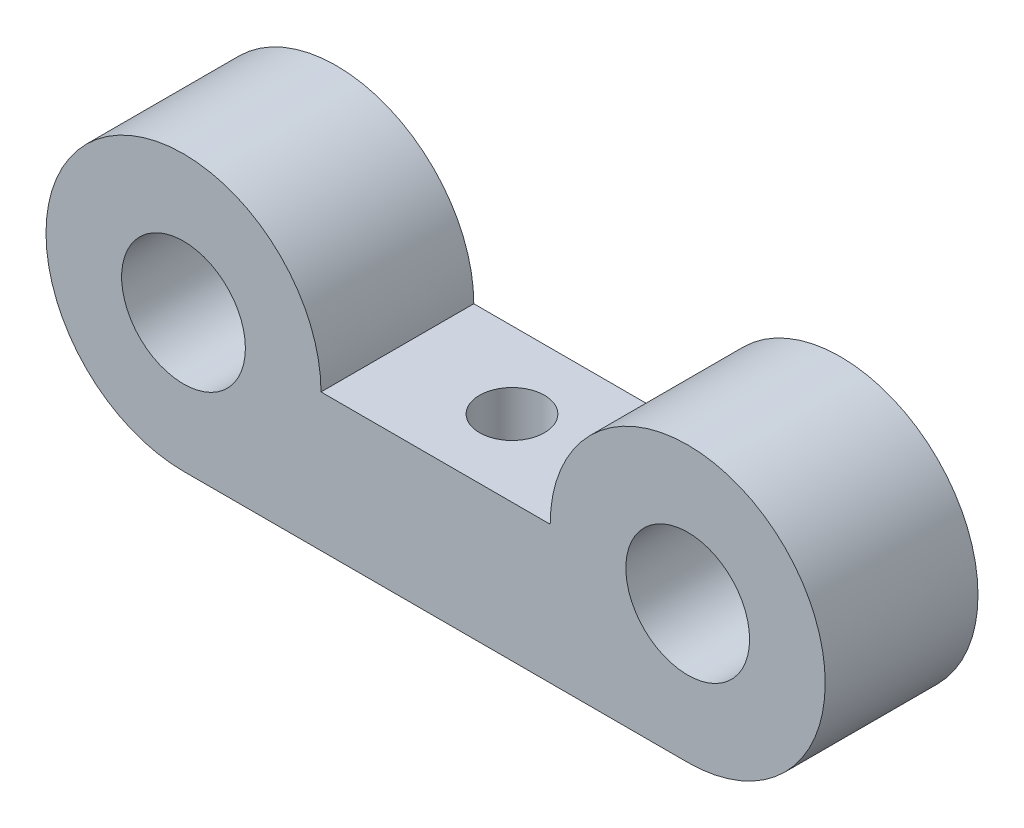
from build123d import *

# Parameters (mm, degrees)
ESBO_O1_R                = 4.05
RESSALTO_EXTRUS_O1_DEPTH = 10
ESBO_O2_R                = 2.125
CORTE_EXTRUS_O1_DEPTH    = 10


with BuildPart() as part:
    # Esboço1 → Ressalto-extrusão1 (new body)
    with BuildSketch(Plane.XY):
        with BuildLine():
            Line((-16.5, -9), (16.5, -9))
            ThreePointArc((16.5, -9), (22.863961031, 6.363961031), (7.5, 0))
            Line((7.5, 0), (-7.5, 0))
            ThreePointArc((-7.5, 0), (-22.863961031, 6.363961031), (-16.5, -9))
        make_face()
        with Locations((-16.5, 0)):
            Circle(ESBO_O1_R, mode=Mode.SUBTRACT)
        with Locations((16.5, 0)):
            Circle(ESBO_O1_R, mode=Mode.SUBTRACT)
    extrude(amount=RESSALTO_EXTRUS_O1_DEPTH)

    # Esboço2 → Corte-extrusão1 (cut)
    with BuildSketch(Plane(origin=(0, 0, 0), x_dir=(1, 0, 0), z_dir=(0, 1, 0))):
        with Locations((0, -5)):
            Circle(ESBO_O2_R)
    extrude(amount=-CORTE_EXTRUS_O1_DEPTH, mode=Mode.SUBTRACT)


solid = part.part
